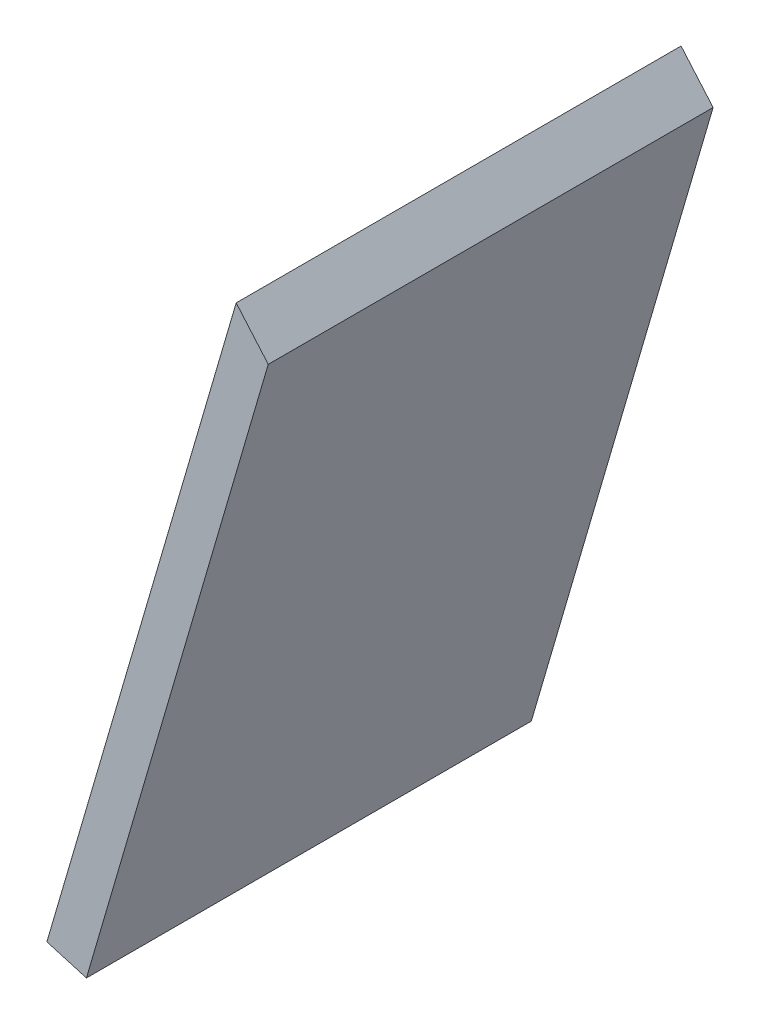
from build123d import *

# Parameters (mm, degrees)
BOSS_EXTRUDE1_DEPTH = 208.295833
SKETCH2_W           = 208.295833075
SKETCH2_H           = 125.616174383
CUT_EXTRUDE1_DEPTH  = 20
SKETCH3_R           = 77.5
CUT_EXTRUDE2_DEPTH  = 155.31


with BuildPart() as part:
    # Sketch1 → Boss-Extrude1 (new body)
    with BuildSketch(Plane.XY.offset(413.892285509)):
        Polygon((-272.519046524, -127.125849596), (-268.630033514, -131.644329993), (-324.842905159, -324.071500461), (-330.714338905, -326.339216919), align=None)
    extrude(amount=BOSS_EXTRUDE1_DEPTH)

    # Sketch2 → Cut-Extrude1 (cut)
    with BuildSketch(Plane(origin=(-212.075436587, 61.95263001, 0), x_dir=(0, 0, -1), z_dir=(0.959881544, -0.280405817, 0))):
        with Locations((-518.040202046, -343.17312855)):
            Rectangle(SKETCH2_W, SKETCH2_H)
    extrude(amount=-CUT_EXTRUDE1_DEPTH, mode=Mode.SUBTRACT)

    # Sketch3 → Cut-Extrude2 (cut, through all)
    with BuildSketch(Plane(origin=(0, 0, 568.202285509), x_dir=(-1, 0, 0), z_dir=(0, 0, -1))):
        with Locations((268.126479956, -164.060077585)):
            Circle(SKETCH3_R)
    extrude(amount=CUT_EXTRUDE2_DEPTH, mode=Mode.SUBTRACT)


solid = part.part
